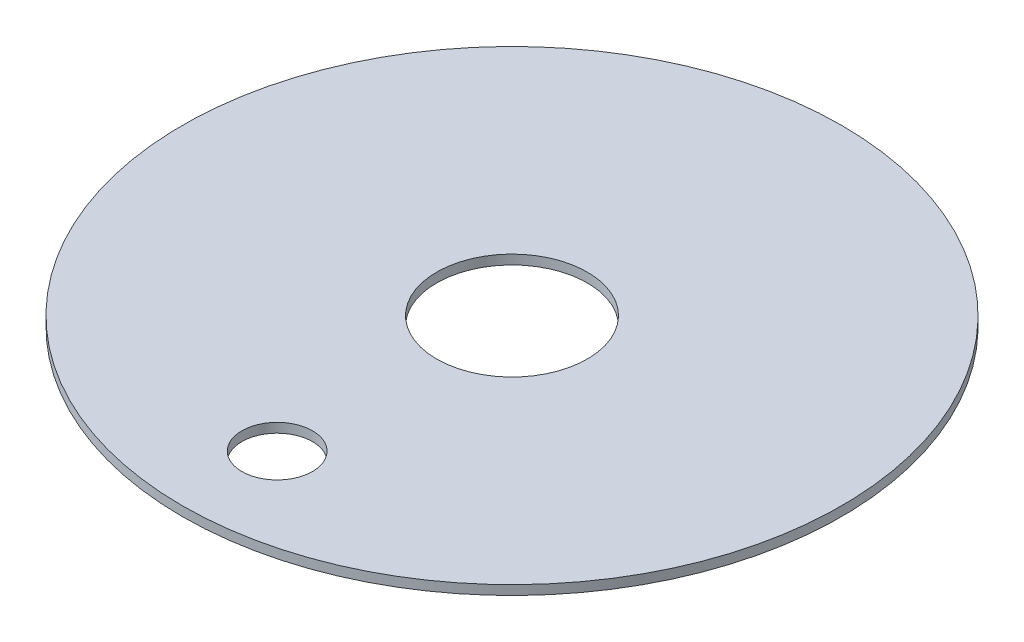
from build123d import *

# Parameters (mm, degrees)
SKETCH1_R           = 70
BOSS_EXTRUDE1_DEPTH = 2
CUT_EXTRUDE2_REACH  = 4
SKETCH5_R           = 16
SKETCH6_R           = 7.5
CUT_EXTRUDE3_DEPTH  = 10
SKETCH7_R           = 1
BOSS_EXTRUDE2_DEPTH = 4
FILLET1_R           = 1


with BuildPart() as part:
    # Sketch1 → Boss-Extrude1 (new body)
    with BuildSketch(Plane(origin=(0, 0, 0), x_dir=(1, 0, 0), z_dir=(0, 1, 0))):
        Circle(SKETCH1_R)
    extrude(amount=BOSS_EXTRUDE1_DEPTH)

    # Sketch5 → Cut-Extrude2 (cut, up to next)
    with BuildSketch(Plane(origin=(0, 2, 0), x_dir=(1, 0, 0), z_dir=(0, 1, 0)), mode=Mode.PRIVATE) as cut_extrude2_sk1:
        Circle(SKETCH5_R)
    cut_extrude2_tool1 = extrude(cut_extrude2_sk1.sketch, amount=-CUT_EXTRUDE2_REACH, mode=Mode.PRIVATE) & part.part
    add(cut_extrude2_tool1.solids().sort_by_distance((0, 2, 0))[0], mode=Mode.SUBTRACT)

    # Sketch6 → Cut-Extrude3 (cut)
    with BuildSketch(Plane(origin=(0, 2, 0), x_dir=(1, 0, 0), z_dir=(0, 1, 0))):
        with Locations((0, -49.88)):
            Circle(SKETCH6_R)
    extrude(amount=-CUT_EXTRUDE3_DEPTH, mode=Mode.SUBTRACT)

    # Sketch7 → Boss-Extrude2 (add)
    with BuildSketch(Plane(origin=(0, 0, 0), x_dir=(1, 0, 0), z_dir=(0, 1, 0))):
        with Locations((0, -60.88)):
            Circle(SKETCH7_R)
    extrude(amount=-BOSS_EXTRUDE2_DEPTH)

    # Fillet1
    fillet1_edges = [part.edges().sort_by_distance(p)[0] for p in [
        (-1, -4, 60.88),
    ]]
    fillet(fillet1_edges, radius=FILLET1_R)


solid = part.part
